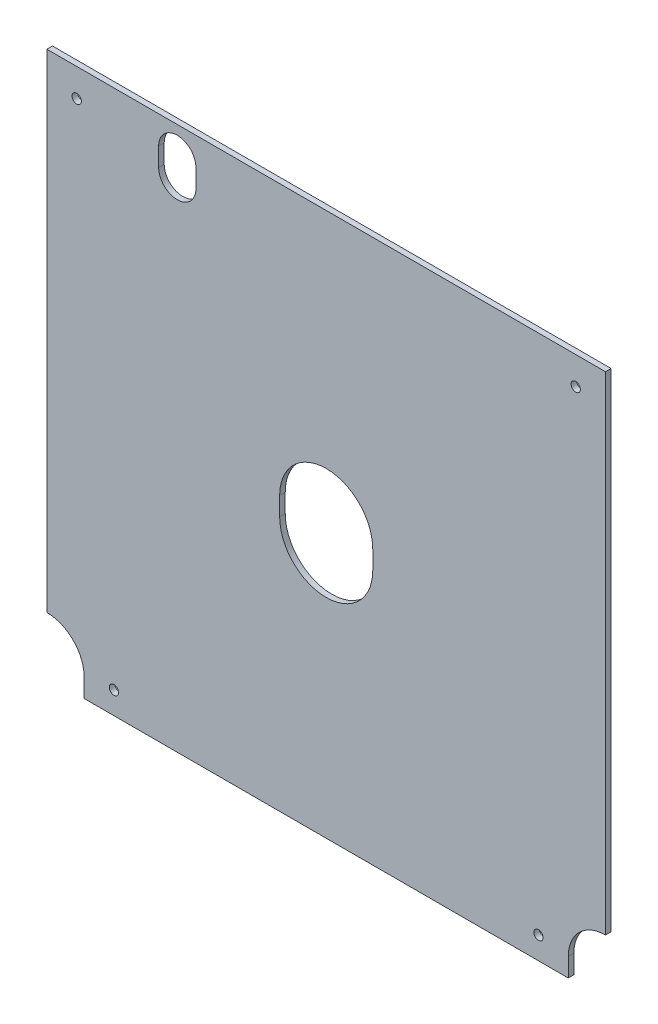
from build123d import *

# Parameters (mm, degrees)
ESQUISSE1_R      = 2.5
EXTRUSION1_DEPTH = 3


with BuildPart() as part:
    # Esquisse1 → Extrusion1 (new body)
    with BuildSketch(Plane.XY):
        with BuildLine():
            Line((150, 292), (-150, 292))
            Line((-150, 292), (-150, 30))
            ThreePointArc((-150, 30), (-135.857864376, 24.142135624), (-130, 10))
            Line((-130, 10), (-130, 0))
            Line((-130, 0), (130, 0))
            Line((130, 0), (130, 10))
            ThreePointArc((130, 10), (135.857864376, 24.142135624), (150, 30))
            Line((150, 30), (150, 292))
        make_face()
        with Locations((134, 277)):
            Circle(ESQUISSE1_R, mode=Mode.SUBTRACT)
        with Locations((-134, 277)):
            Circle(ESQUISSE1_R, mode=Mode.SUBTRACT)
        with Locations((114, 12)):
            Circle(ESQUISSE1_R, mode=Mode.SUBTRACT)
        with Locations((-114, 12)):
            Circle(ESQUISSE1_R, mode=Mode.SUBTRACT)
        with BuildLine():
            Line((-25, 137), (-25, 147))
            ThreePointArc((-25, 147), (0, 172), (25, 147))
            Line((25, 147), (25, 137))
            ThreePointArc((25, 137), (0, 112), (-25, 137))
        make_face(mode=Mode.SUBTRACT)
        with BuildLine():
            Line((-90, 267), (-90, 277))
            ThreePointArc((-90, 277), (-80, 287), (-70, 277))
            Line((-70, 277), (-70, 267))
            ThreePointArc((-70, 267), (-80, 257), (-90, 267))
        make_face(mode=Mode.SUBTRACT)
    extrude(amount=EXTRUSION1_DEPTH)


solid = part.part
